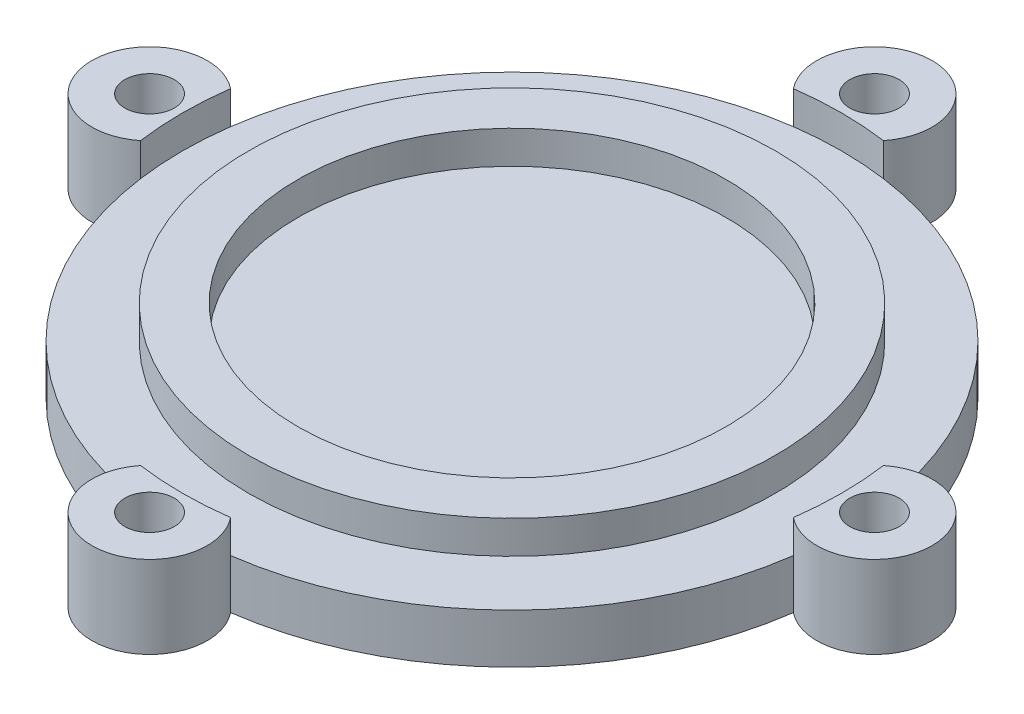
from build123d import *

# Parameters (mm, degrees)
SKETCH1_R           = 1.5
BOSS_EXTRUDE1_DEPTH = 3
BOSS_EXTRUDE2_START = 3
SKETCH1_4_R         = 1.5
SKETCH1_4_R_2       = 16
SKETCH1_4_R_3       = 13
BOSS_EXTRUDE2_DEPTH = 2


with BuildPart() as part:
    # Sketch1 → Boss-Extrude1 (new body)
    with BuildSketch(Plane(origin=(0, 0, 0), x_dir=(1, 0, 0), z_dir=(0, 1, 0))):
        with BuildLine():
            ThreePointArc((19.8125, 2.732186624), (14.142135624, 14.142135624), (2.732186624, 19.8125))
            ThreePointArc((2.732186624, 19.8125), (0, 25.5), (-2.732186624, 19.8125))
            ThreePointArc((-2.732186624, 19.8125), (-14.142135624, 14.142135624), (-19.8125, 2.732186624))
            ThreePointArc((-19.8125, 2.732186624), (-25.5, 0), (-19.8125, -2.732186624))
            ThreePointArc((-19.8125, -2.732186624), (-14.142135624, -14.142135624), (-2.732186624, -19.8125))
            ThreePointArc((-2.732186624, -19.8125), (0, -25.5), (2.732186624, -19.8125))
            ThreePointArc((2.732186624, -19.8125), (14.142135624, -14.142135624), (19.8125, -2.732186624))
            ThreePointArc((19.8125, -2.732186624), (25.5, 0), (19.8125, 2.732186624))
        make_face()
        with Locations((22, 0)):
            Circle(SKETCH1_R, mode=Mode.SUBTRACT)
        with Locations((0, 22)):
            Circle(SKETCH1_R, mode=Mode.SUBTRACT)
        with Locations((0, -22)):
            Circle(SKETCH1_R, mode=Mode.SUBTRACT)
        with Locations((-22, 0)):
            Circle(SKETCH1_R, mode=Mode.SUBTRACT)
    extrude(amount=BOSS_EXTRUDE1_DEPTH)

    # Sketch1_4 → Boss-Extrude2 (add)
    with BuildSketch(Plane(origin=(0, 0, 0), x_dir=(1, 0, 0), z_dir=(0, 1, 0)).offset(BOSS_EXTRUDE2_START)):
        with BuildLine():
            ThreePointArc((-2.732186624, -19.8125), (0, -25.5), (2.732186624, -19.8125))
            ThreePointArc((2.732186624, -19.8125), (0, -20), (-2.732186624, -19.8125))
        make_face()
        with Locations((0, -22)):
            Circle(SKETCH1_4_R, mode=Mode.SUBTRACT)
        with BuildLine():
            ThreePointArc((19.8125, 2.732186624), (19.953069939, 1.369306394), (20, 0))
            ThreePointArc((20, 0), (19.953069939, -1.369306394), (19.8125, -2.732186624))
            ThreePointArc((19.8125, -2.732186624), (25.5, 0), (19.8125, 2.732186624))
        make_face()
        with Locations((22, 0)):
            Circle(SKETCH1_4_R, mode=Mode.SUBTRACT)
        with BuildLine():
            ThreePointArc((-2.732186624, 19.8125), (0, 20), (2.732186624, 19.8125))
            ThreePointArc((2.732186624, 19.8125), (0, 25.5), (-2.732186624, 19.8125))
        make_face()
        with Locations((0, 22)):
            Circle(SKETCH1_4_R, mode=Mode.SUBTRACT)
        with BuildLine():
            ThreePointArc((-19.8125, -2.732186624), (-20, 0), (-19.8125, 2.732186624))
            ThreePointArc((-19.8125, 2.732186624), (-25.5, 0), (-19.8125, -2.732186624))
        make_face()
        with Locations((-22, 0)):
            Circle(SKETCH1_4_R, mode=Mode.SUBTRACT)
        Circle(SKETCH1_4_R_2)
        Circle(SKETCH1_4_R_3, mode=Mode.SUBTRACT)
    extrude(amount=BOSS_EXTRUDE2_DEPTH)


solid = part.part
